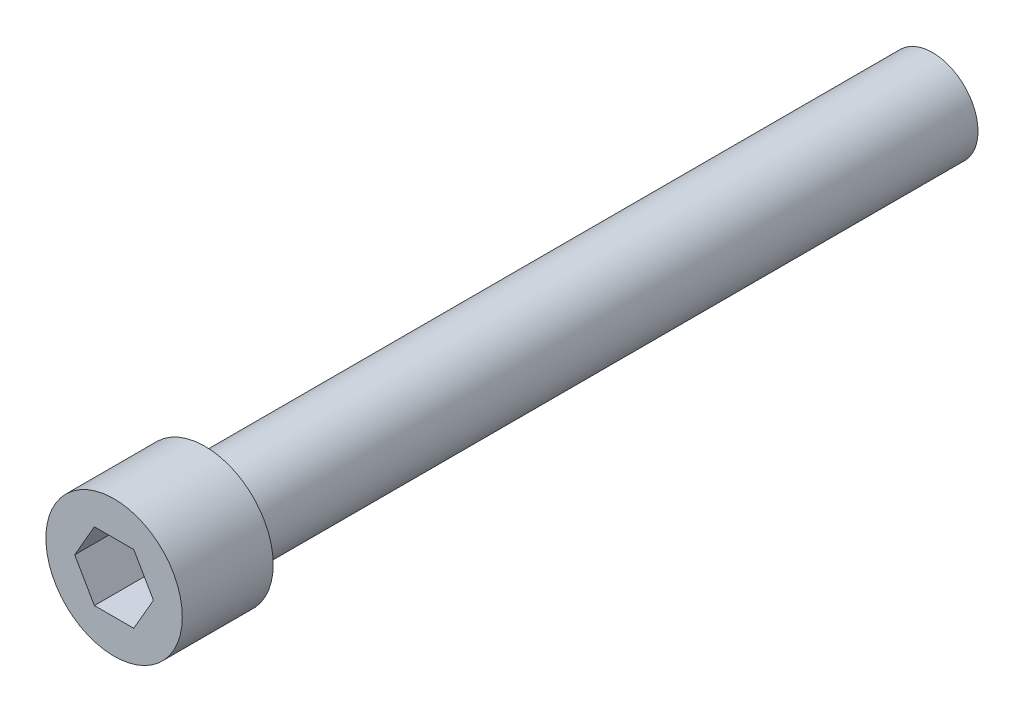
from build123d import *

# Parameters (mm, degrees)
SKETCH1_R           = 3.175
BOSS_EXTRUDE1_DEPTH = 50.8
SKETCH2_R           = 4.7625
BOSS_EXTRUDE2_DEPTH = 6.35
CUT_EXTRUDE1_DEPTH  = 3.5814


with BuildPart() as part:
    # Sketch1 → Boss-Extrude1 (new body)
    with BuildSketch(Plane.XY):
        Circle(SKETCH1_R)
    extrude(amount=BOSS_EXTRUDE1_DEPTH)

    # Sketch2 → Boss-Extrude2 (add)
    with BuildSketch(Plane.XY.offset(50.8)):
        Circle(SKETCH2_R)
    extrude(amount=BOSS_EXTRUDE2_DEPTH)

    # Sketch3 → Cut-Extrude1 (cut)
    with BuildSketch(Plane.XY.offset(57.15)):
        Polygon((2.749630657, 0), (1.374815329, 2.38125), (-1.374815329, 2.38125), (-2.749630657, 0), (-1.374815329, -2.38125), (1.374815329, -2.38125), align=None)
    extrude(amount=-CUT_EXTRUDE1_DEPTH, mode=Mode.SUBTRACT)


solid = part.part
